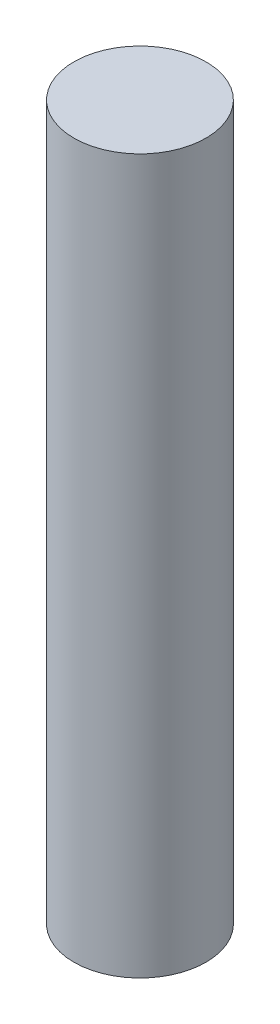
from build123d import *

# Parameters (mm, degrees)
SKETCH1_R           = 2.5
BOSS_EXTRUDE1_DEPTH = 13.5


with BuildPart() as part:
    # Sketch1 → Boss-Extrude1 (new body, symmetric)
    with BuildSketch(Plane(origin=(0, 0, 0), x_dir=(1, 0, 0), z_dir=(0, 1, 0))):
        Circle(SKETCH1_R)
    extrude(amount=BOSS_EXTRUDE1_DEPTH, both=True)


solid = part.part
